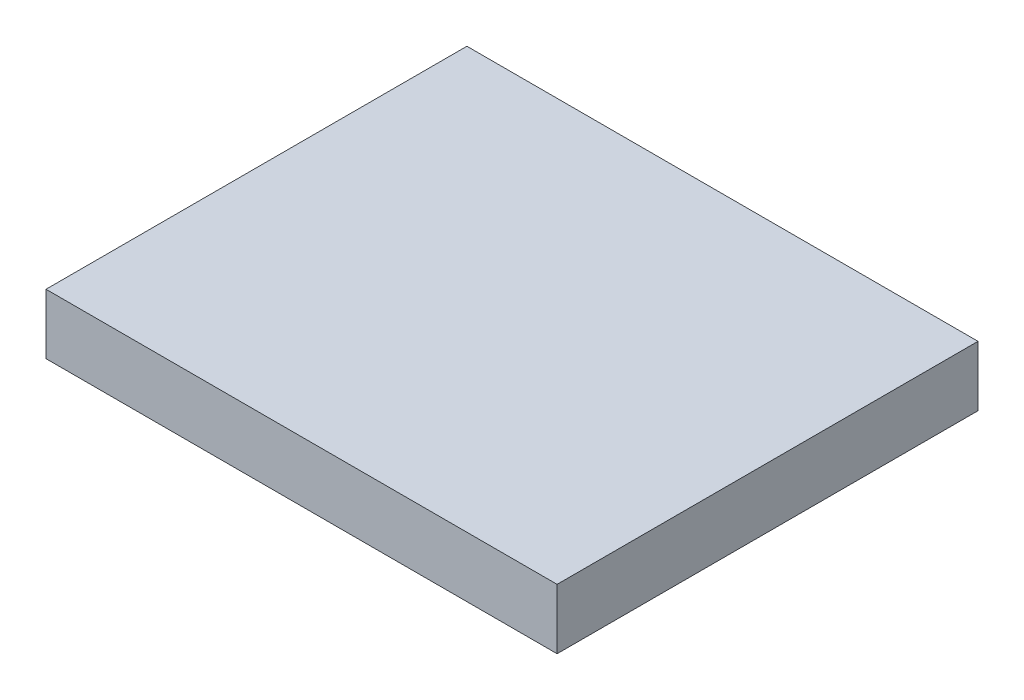
from build123d import *

# Parameters (mm, degrees)
SKETCH2_W           = 17
SKETCH2_H           = 14
BOSS_EXTRUDE1_DEPTH = 2


with BuildPart() as part:
    # Sketch2 → Boss-Extrude1 (new body)
    with BuildSketch(Plane(origin=(0, 0, 0), x_dir=(1, 0, 0), z_dir=(0, 1, 0))):
        with Locations((-3.467567568, -0.151351351)):
            Rectangle(SKETCH2_W, SKETCH2_H)
    extrude(amount=BOSS_EXTRUDE1_DEPTH)


solid = part.part
